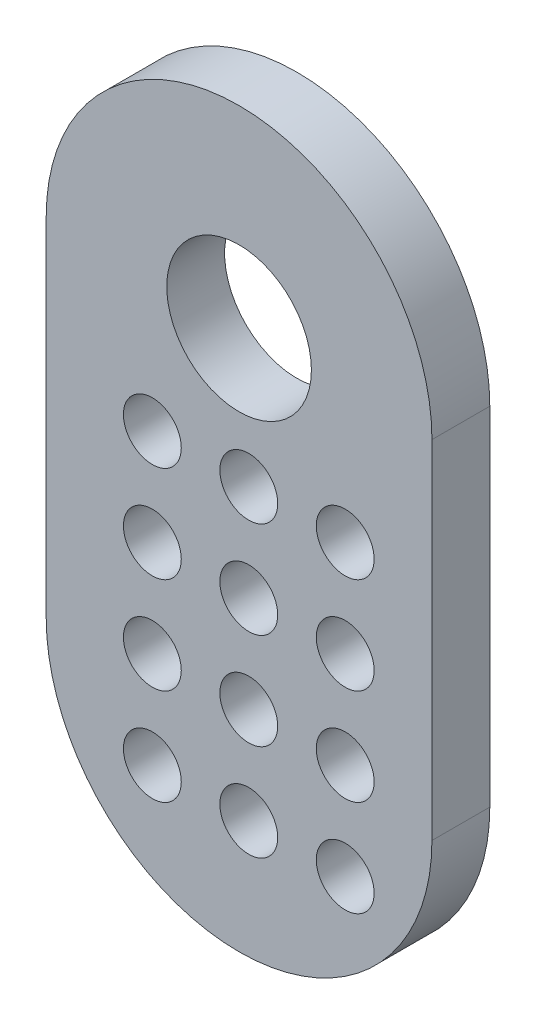
from build123d import *

# Parameters (mm, degrees)
ESQUISSE1_R        = 3.75
ESQUISSE1_R_2      = 1.5
BOSS_EXTRU_1_DEPTH = 3


with BuildPart() as part:
    # Esquisse1 → Boss.-Extru.1 (new body)
    with BuildSketch(Plane.XY):
        with BuildLine():
            Line((-10, -18), (-10, 0))
            ThreePointArc((-10, 0), (0, 10), (10, 0))
            Line((10, 0), (10, -18))
            ThreePointArc((10, -18), (0, -28), (-10, -18))
        make_face()
        Circle(ESQUISSE1_R, mode=Mode.SUBTRACT)
        with Locations((-4.496614477, -21.867219529)):
            Circle(ESQUISSE1_R_2, mode=Mode.SUBTRACT)
        with Locations((0.503385523, -21.867219529)):
            Circle(ESQUISSE1_R_2, mode=Mode.SUBTRACT)
        with Locations((5.503385523, -21.867219529)):
            Circle(ESQUISSE1_R_2, mode=Mode.SUBTRACT)
        with Locations((0.503385523, -16.867219529)):
            Circle(ESQUISSE1_R_2, mode=Mode.SUBTRACT)
        with Locations((5.503385523, -16.867219529)):
            Circle(ESQUISSE1_R_2, mode=Mode.SUBTRACT)
        with Locations((0.503385523, -11.867219529)):
            Circle(ESQUISSE1_R_2, mode=Mode.SUBTRACT)
        with Locations((5.503385523, -11.867219529)):
            Circle(ESQUISSE1_R_2, mode=Mode.SUBTRACT)
        with Locations((0.503385523, -6.867219529)):
            Circle(ESQUISSE1_R_2, mode=Mode.SUBTRACT)
        with Locations((5.503385523, -6.867219529)):
            Circle(ESQUISSE1_R_2, mode=Mode.SUBTRACT)
        with Locations((-4.496614477, -16.867219529)):
            Circle(ESQUISSE1_R_2, mode=Mode.SUBTRACT)
        with Locations((-4.496614477, -11.867219529)):
            Circle(ESQUISSE1_R_2, mode=Mode.SUBTRACT)
        with Locations((-4.496614477, -6.867219529)):
            Circle(ESQUISSE1_R_2, mode=Mode.SUBTRACT)
    extrude(amount=BOSS_EXTRU_1_DEPTH)


solid = part.part
